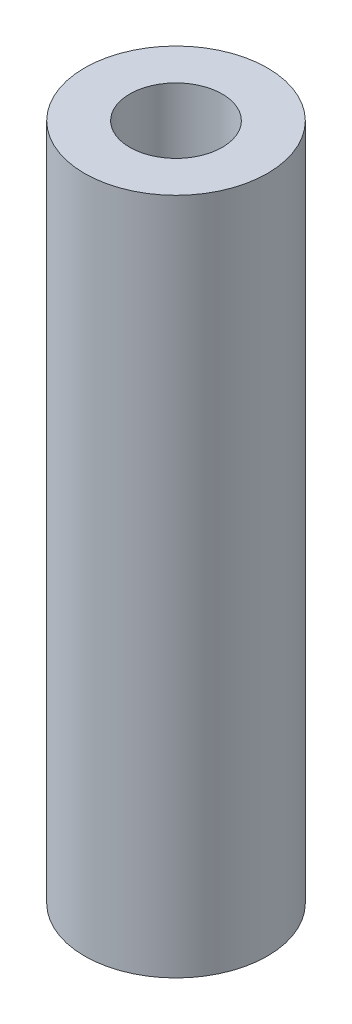
from build123d import *

# Parameters (mm, degrees)
SKETCH1_R           = 5.14
SKETCH1_R_2         = 2.6
BOSS_EXTRUDE1_DEPTH = 38.1


with BuildPart() as part:
    # Sketch1 → Boss-Extrude1 (new body)
    with BuildSketch(Plane(origin=(0, 0, 0), x_dir=(1, 0, 0), z_dir=(0, 1, 0))):
        Circle(SKETCH1_R)
        Circle(SKETCH1_R_2, mode=Mode.SUBTRACT)
    extrude(amount=BOSS_EXTRUDE1_DEPTH)


solid = part.part
